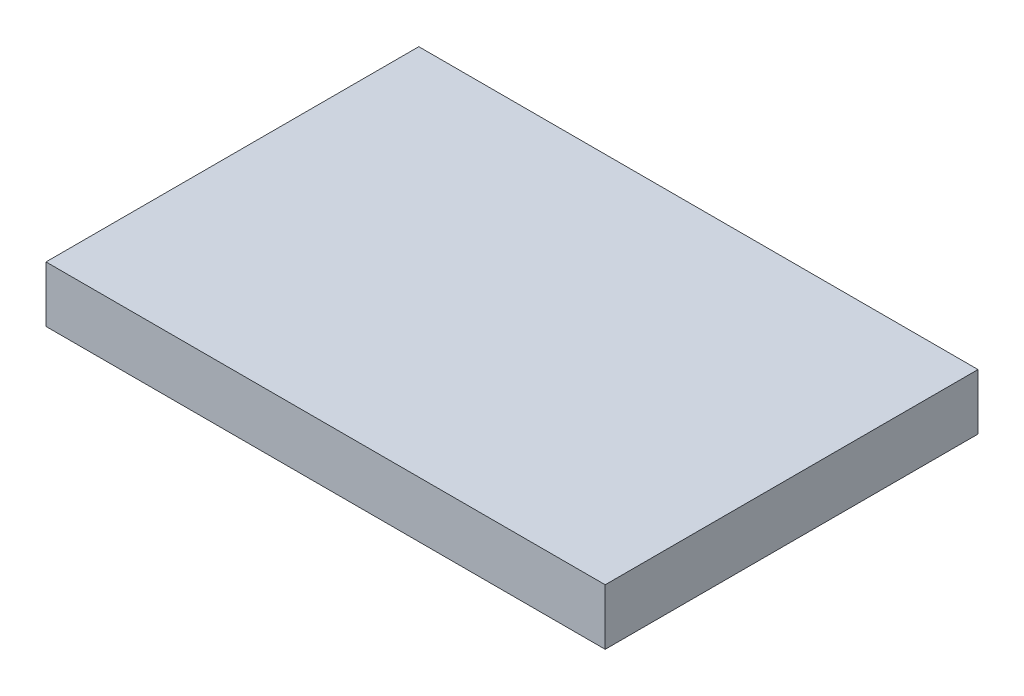
from build123d import *

# Parameters (mm, degrees)
SKETCH1_W           = 30
SKETCH1_H           = 20
BOSS_EXTRUDE1_DEPTH = 3


with BuildPart() as part:
    # Sketch1 → Boss-Extrude1 (new body)
    with BuildSketch(Plane(origin=(0, 0, 0), x_dir=(1, 0, 0), z_dir=(0, 1, 0))):
        Rectangle(SKETCH1_W, SKETCH1_H)
    extrude(amount=BOSS_EXTRUDE1_DEPTH)


solid = part.part
